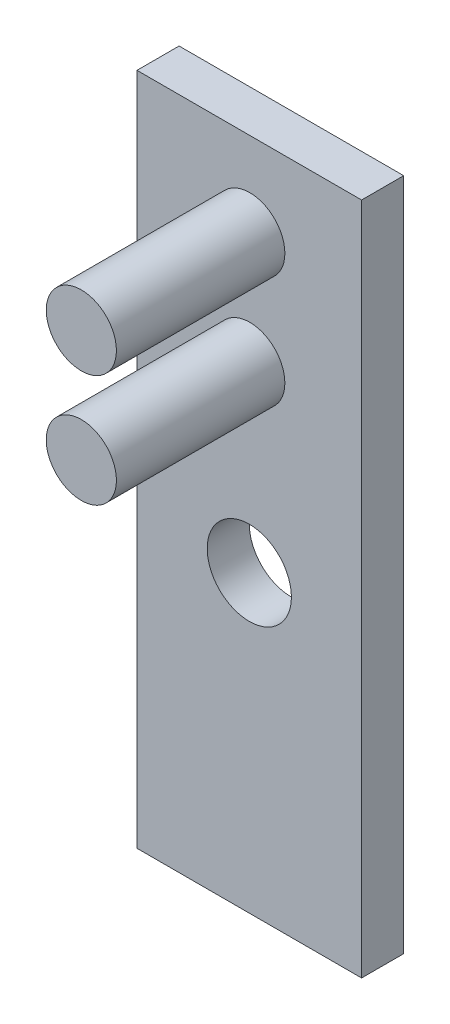
from build123d import *

# Parameters (mm, degrees)
SKETCH1_W           = 8
SKETCH1_H           = 24
BOSS_EXTRUDE1_DEPTH = 1.5
SKETCH2_R           = 1.5
CUT_EXTRUDE1_DEPTH  = 2.5
SKETCH3_R           = 1.25
BOSS_EXTRUDE3_DEPTH = 6


with BuildPart() as part:
    # Sketch1 → Boss-Extrude1 (new body)
    with BuildSketch(Plane.XY):
        with Locations((-11.98249453, -3.04595186)):
            Rectangle(SKETCH1_W, SKETCH1_H)
    extrude(amount=BOSS_EXTRUDE1_DEPTH)

    # Sketch2 → Cut-Extrude1 (cut, through all)
    with BuildSketch(Plane.XY.offset(1.5)):
        with Locations((-11.98249453, -4.54595186)):
            Circle(SKETCH2_R)
    extrude(amount=-CUT_EXTRUDE1_DEPTH, mode=Mode.SUBTRACT)

    # Sketch3 → Boss-Extrude3 (add)
    with BuildSketch(Plane.XY.offset(1.5)):
        with Locations((-11.965684197, 5.940322957)):
            Circle(SKETCH3_R)
        with Locations((-11.965684197, 1.940322957)):
            Circle(SKETCH3_R)
    extrude(amount=BOSS_EXTRUDE3_DEPTH)


solid = part.part
